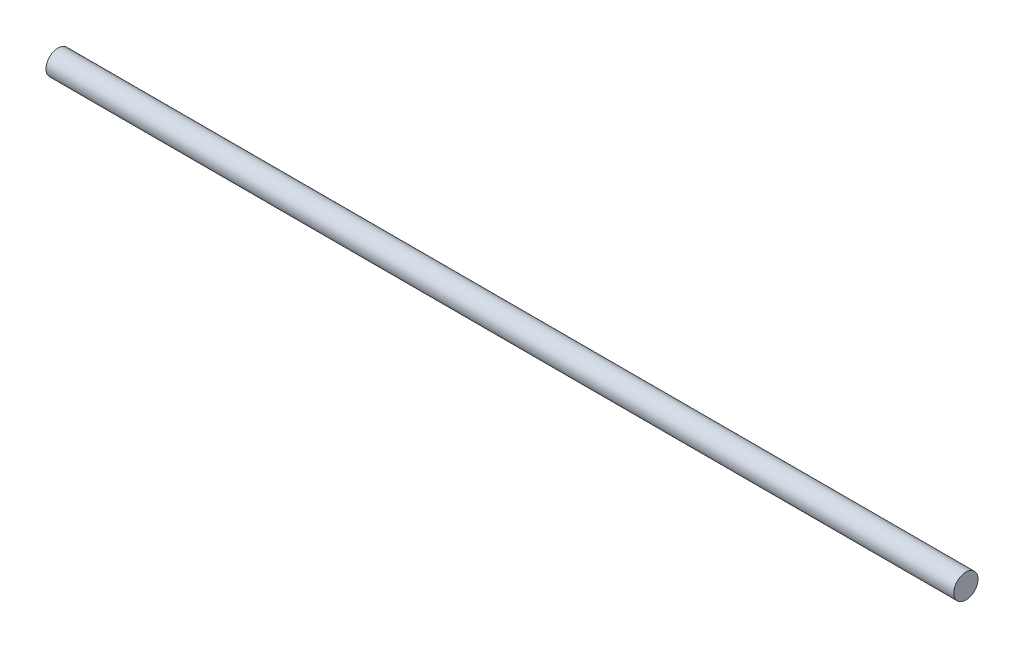
from build123d import *

# Parameters (mm, degrees)
SKETCH1_R           = 2
BOSS_EXTRUDE1_DEPTH = 150


with BuildPart() as part:
    # Sketch1 → Boss-Extrude1 (new body)
    with BuildSketch(Plane(origin=(0, 0, 0), x_dir=(0, 0, -1), z_dir=(1, 0, 0))):
        Circle(SKETCH1_R)
    extrude(amount=BOSS_EXTRUDE1_DEPTH)


solid = part.part
